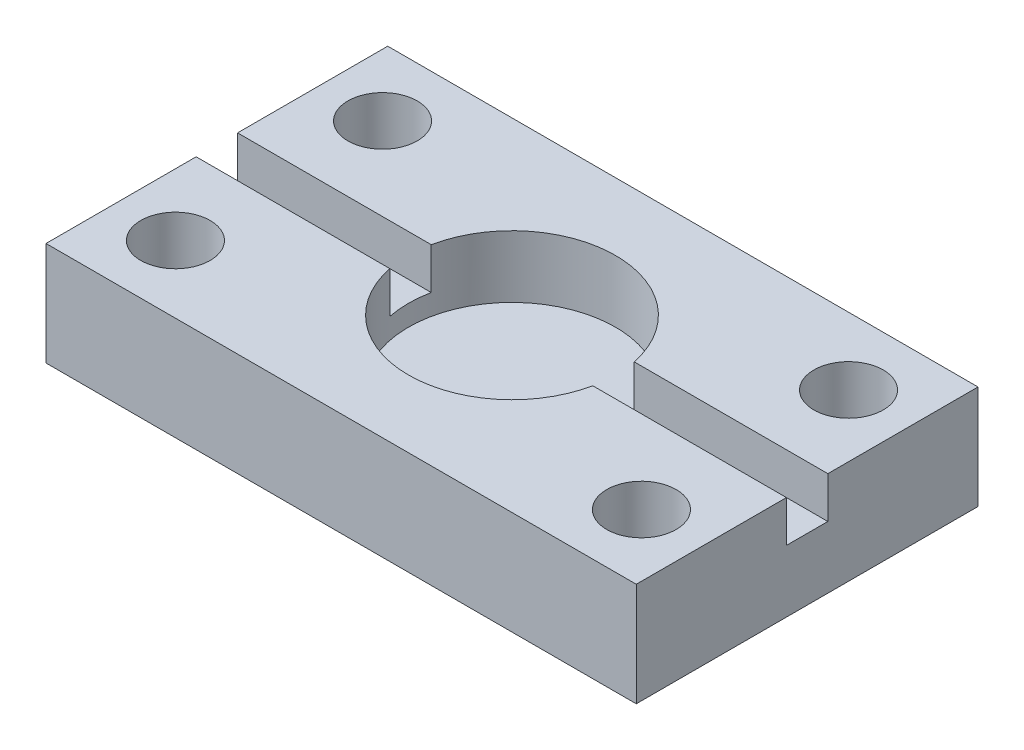
from build123d import *

# Parameters (mm, degrees)
SKETCH1_W           = 57
SKETCH1_H           = 33
BOSS_EXTRUDE1_DEPTH = 10
SKETCH3_R           = 3.35
CUT_EXTRUDE1_DEPTH  = 11
SKETCH4_R           = 3.35
CUT_EXTRUDE2_DEPTH  = 11
SKETCH10_R          = 3.35
CUT_EXTRUDE5_DEPTH  = 11
SKETCH12_R          = 3.35
CUT_EXTRUDE6_DEPTH  = 11
SKETCH16_W          = 57
SKETCH16_H          = 4
CUT_EXTRUDE7_DEPTH  = 4
SKETCH17_R          = 10
CUT_EXTRUDE8_DEPTH  = 6


with BuildPart() as part:
    # Sketch1 → Boss-Extrude1 (new body)
    with BuildSketch(Plane(origin=(0, 0, 0), x_dir=(1, 0, 0), z_dir=(0, 1, 0))):
        with Locations((28.5, 16.5)):
            Rectangle(SKETCH1_W, SKETCH1_H)
    extrude(amount=BOSS_EXTRUDE1_DEPTH)

    # Sketch3 → Cut-Extrude1 (cut, through all)
    with BuildSketch(Plane.XZ):
        with Locations((6, -6.5)):
            Circle(SKETCH3_R)
    extrude(amount=-CUT_EXTRUDE1_DEPTH, mode=Mode.SUBTRACT)

    # Sketch4 → Cut-Extrude2 (cut, through all)
    with BuildSketch(Plane.XZ):
        with Locations((51, -26.5)):
            Circle(SKETCH4_R)
    extrude(amount=-CUT_EXTRUDE2_DEPTH, mode=Mode.SUBTRACT)

    # Sketch10 → Cut-Extrude5 (cut, through all)
    with BuildSketch(Plane.XZ):
        with Locations((6, -26.5)):
            Circle(SKETCH10_R)
    extrude(amount=-CUT_EXTRUDE5_DEPTH, mode=Mode.SUBTRACT)

    # Sketch12 → Cut-Extrude6 (cut, through all)
    with BuildSketch(Plane.XZ):
        with Locations((51, -6.5)):
            Circle(SKETCH12_R)
    extrude(amount=-CUT_EXTRUDE6_DEPTH, mode=Mode.SUBTRACT)

    # Sketch16 → Cut-Extrude7 (cut)
    with BuildSketch(Plane(origin=(0, 10, 0), x_dir=(1, 0, 0), z_dir=(0, 1, 0))):
        with Locations((28.5, 16.5)):
            Rectangle(SKETCH16_W, SKETCH16_H)
    extrude(amount=-CUT_EXTRUDE7_DEPTH, mode=Mode.SUBTRACT)

    # Sketch17 → Cut-Extrude8 (cut)
    with BuildSketch(Plane(origin=(0, 10, 0), x_dir=(1, 0, 0), z_dir=(0, 1, 0))):
        with Locations((28.5, 16.5)):
            Circle(SKETCH17_R)
    extrude(amount=-CUT_EXTRUDE8_DEPTH, mode=Mode.SUBTRACT)


solid = part.part
